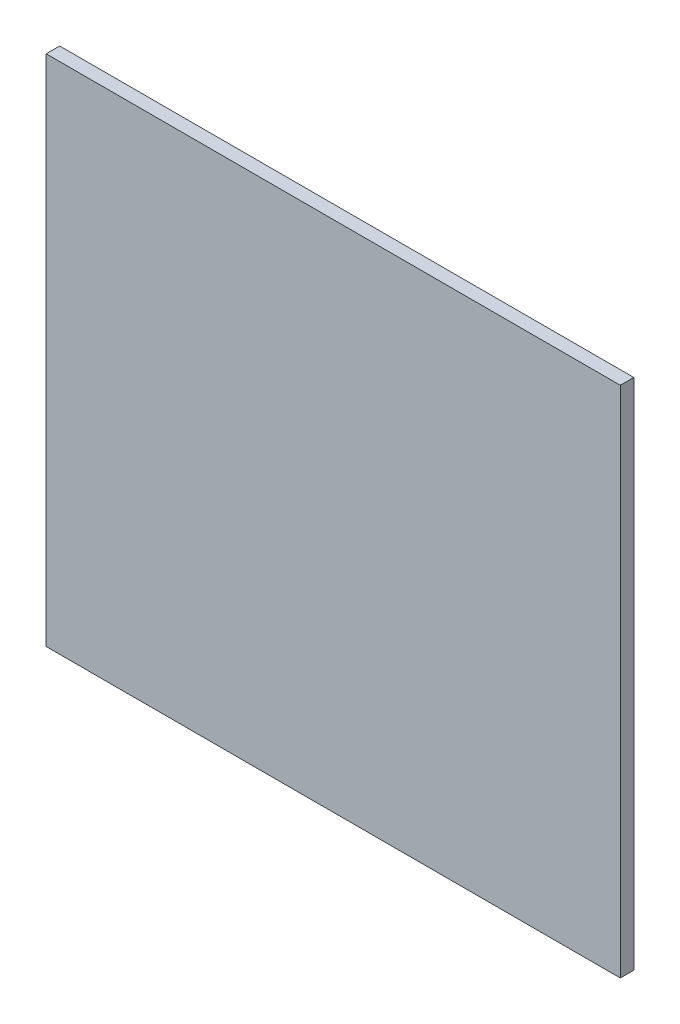
from build123d import *

# Parameters (mm, degrees)
SKETCH1_W           = 425
SKETCH1_H           = 380
BOSS_EXTRUDE1_DEPTH = 10


with BuildPart() as part:
    # Sketch1 → Boss-Extrude1 (new body)
    with BuildSketch(Plane.XY):
        Rectangle(SKETCH1_W, SKETCH1_H)
    extrude(amount=BOSS_EXTRUDE1_DEPTH)


solid = part.part
